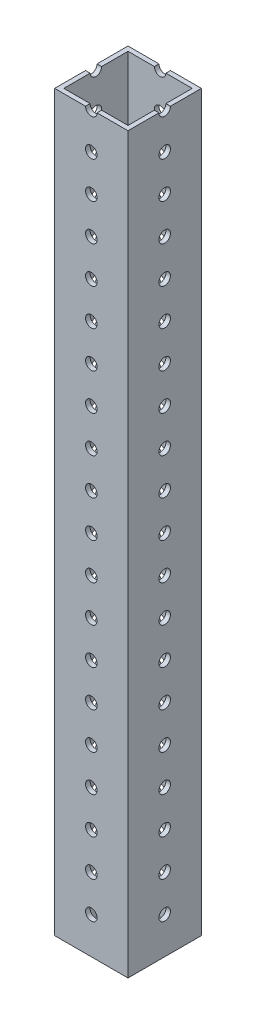
from build123d import *

# Parameters (mm, degrees)
SKETCH1_W                   = 25.4
SKETCH1_H                   = 25.4
SKETCH1_W_2                 = 22.225
SKETCH1_H_2                 = 22.225
BOSS_EXTRUDE1_DEPTH         = 254
F_22_0_157_DIAMETER_HOLE1_D = 3.9878
LPATTERN1_COUNT             = 20
LPATTERN1_PITCH             = 12.7
F_22_0_157_DIAMETER_HOLE2_D = 3.9878
LPATTERN2_COUNT             = 20
LPATTERN2_PITCH             = 12.7


with BuildPart() as part:
    # Sketch1 → Boss-Extrude1 (new body)
    with BuildSketch(Plane(origin=(0, 0, 0), x_dir=(1, 0, 0), z_dir=(0, 1, 0))):
        Rectangle(SKETCH1_W, SKETCH1_H)
        Rectangle(SKETCH1_W_2, SKETCH1_H_2, mode=Mode.SUBTRACT)
    extrude(amount=BOSS_EXTRUDE1_DEPTH)

    # #22 (0.157) Diameter Hole1 (through all)
    with Locations(Plane.XY.offset(12.7)):
        with Locations((0, 12.7)):
            f_22_0_157_diameter_hole1 = Hole(F_22_0_157_DIAMETER_HOLE1_D / 2)

    # LPattern1: #22 (0.157) Diameter Hole1 ×20
    with Locations(*[(0, i * LPATTERN1_PITCH, 0) for i in range(1, LPATTERN1_COUNT)]):
        add(f_22_0_157_diameter_hole1, mode=Mode.SUBTRACT)

    # #22 (0.157) Diameter Hole2 (through all)
    with Locations(Plane(origin=(12.7, 0, 0), x_dir=(0, 0, -1), z_dir=(1, 0, 0))):
        with Locations((0, 12.7)):
            f_22_0_157_diameter_hole2 = Hole(F_22_0_157_DIAMETER_HOLE2_D / 2)

    # LPattern2: #22 (0.157) Diameter Hole2 ×20
    with Locations(*[(0, i * LPATTERN2_PITCH, 0) for i in range(1, LPATTERN2_COUNT)]):
        add(f_22_0_157_diameter_hole2, mode=Mode.SUBTRACT)


solid = part.part
